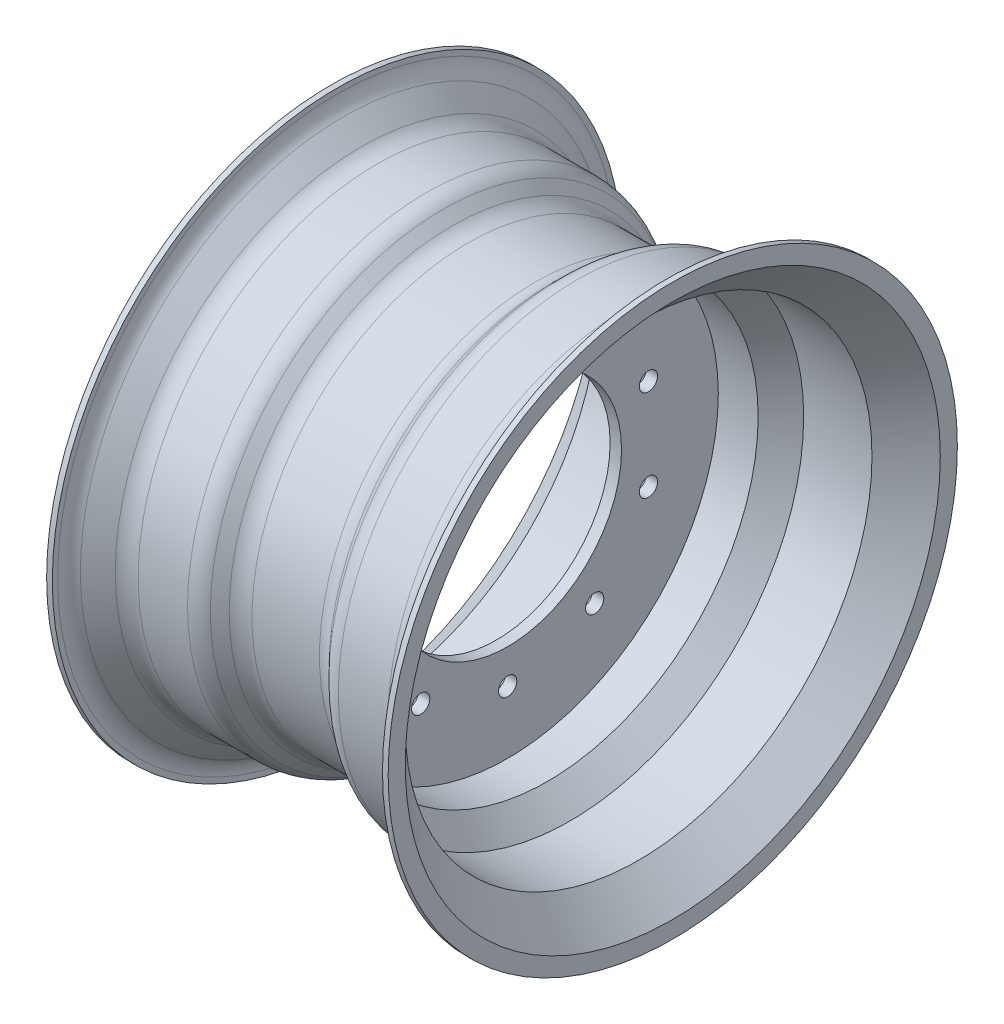
from build123d import *

# Parameters (mm, degrees)
FILLET1_R          = 20
SKETCH2_R          = 8
CUT_EXTRUDE1_DEPTH = 10
CIRPATTERN1_COUNT  = 10


with BuildPart() as part:
    # Sketch1 → Revolve1 (revolve)
    with BuildSketch(Plane.XY):
        Polygon((-150, 250), (-150, 235), (-120, 205), (-60, 205), (-40, 185), (-5, 185), (-5, 100), (5, 100), (5, 185), (40, 185), (60, 205), (120, 205), (150, 235), (150, 250), (145, 250), (145, 237.071067812), (117.928932188, 210), (57.928932188, 210), (37.928932188, 190), (-37.928932188, 190), (-57.928932188, 210), (-117.928932188, 210), (-145, 237.071067812), (-145, 250), align=None)
    revolve(axis=Axis((0, 0, 0), (-1, 0, 0)))

    # Fillet1
    fillet1_edges = [part.edges().sort_by_distance(p)[0] for p in [
        (145, -237.071067812, 0),
        (117.928932188, -210, 0),
        (57.928932188, -210, 0),
        (37.928932188, -190, 0),
        (-37.928932188, -190, 0),
        (-57.928932188, -210, 0),
        (-117.928932188, -210, 0),
        (-145, -237.071067812, 0),
    ]]
    fillet(fillet1_edges, radius=FILLET1_R)

    # Sketch2 → Cut-Extrude1 (cut)
    with BuildSketch(Plane(origin=(5, 0, 0), x_dir=(0, 0, -1), z_dir=(1, 0, 0))):
        with Locations((0, 130)):
            Circle(SKETCH2_R)
    cut_extrude1 = extrude(amount=-CUT_EXTRUDE1_DEPTH, mode=Mode.SUBTRACT)

    # CirPattern1: Cut-Extrude1 ×10 about axis
    cirpattern1_axis = Axis((0, 0, 0), (1, 0, 0))
    for i in range(1, CIRPATTERN1_COUNT):
        add(cut_extrude1.rotate(cirpattern1_axis, i * 360 / CIRPATTERN1_COUNT), mode=Mode.SUBTRACT)


solid = part.part
